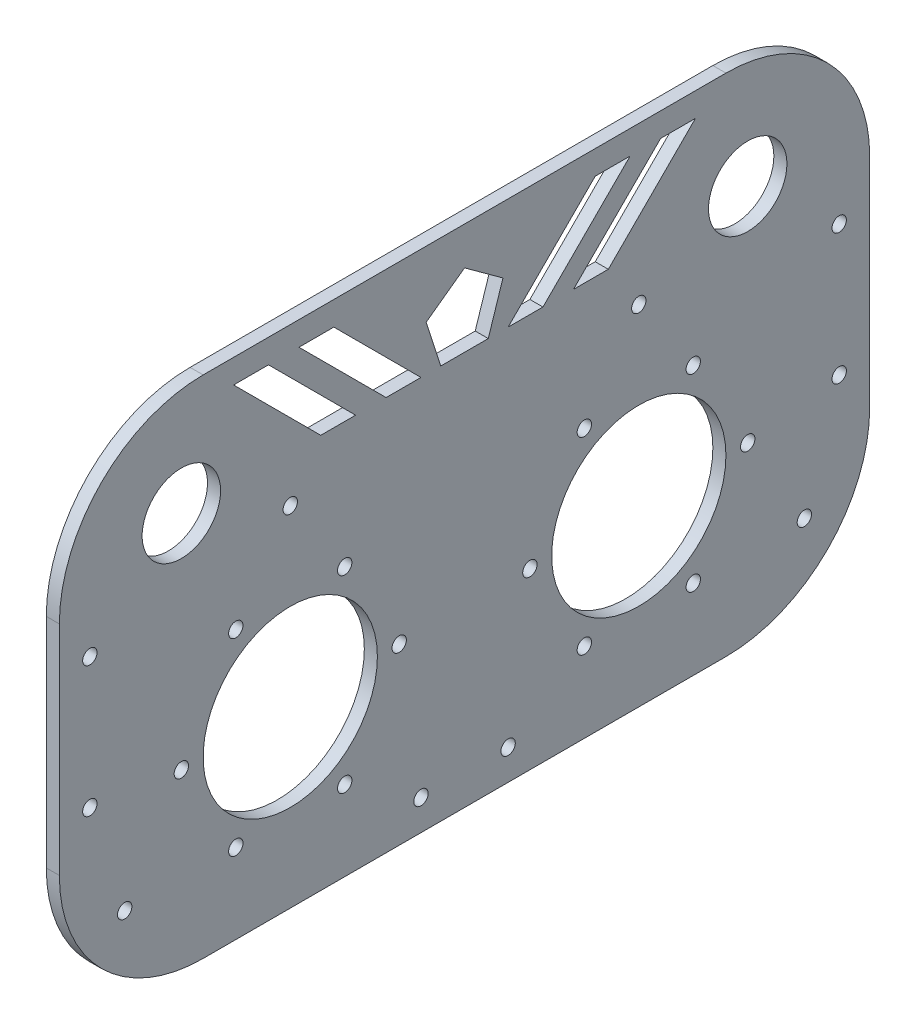
from build123d import *

# Parameters (mm, degrees)
SKETCH_1_W           = 120
SKETCH_1_H           = 83
SKETCH_1_H_2         = 33
EXTRUDE_2_DEPTH      = 3
SKETCH_2_R           = 1.65
SKETCH_2_R_2         = 20
CUT_EXTRUDE_1_DEPTH  = 3
SKETCH_3_R           = 1.65
CUT_EXTRUDE_2_DEPTH  = 10
SKETCH_4_R           = 1.65
CUT_EXTRUDE_3_DEPTH  = 5
CUT_EXTRUDE_6_DEPTH  = 3
SKETCH_9_W           = 5
SKETCH_9_H           = 5
EXTRUDE_4_DEPTH      = 2.25
SKETCH_8_R           = 1.65
CUT_EXTRUDE_9_DEPTH  = 7
SKETCH_11_R          = 9
CUT_EXTRUDE_10_DEPTH = 10


with BuildPart() as part:
    # 草图1 → 凸台-拉伸2 (new body)
    with BuildSketch(Plane(origin=(0, 0, 0), x_dir=(0, 0, -1), z_dir=(1, 0, 0))):
        with Locations((0, -16.5)):
            Rectangle(SKETCH_1_W, SKETCH_1_H)
        with Locations((0, 41.5)):
            Rectangle(SKETCH_1_W, SKETCH_1_H_2)
        with BuildLine():
            Line((-60, -58), (-60, 58))
            ThreePointArc((-60, 58), (-83.334523779, 48.334523779), (-93, 25))
            Line((-93, 25), (-93, -25))
            ThreePointArc((-93, -25), (-83.334523779, -48.334523779), (-60, -58))
        make_face()
        with BuildLine():
            ThreePointArc((60, 58), (83.334523779, 48.334523779), (93, 25))
            Line((93, 25), (93, -25))
            ThreePointArc((93, -25), (83.334523779, -48.334523779), (60, -58))
            Line((60, -58), (60, 58))
        make_face()
    extrude(amount=EXTRUDE_2_DEPTH)

    # 草图2 → 切除-拉伸1 (cut)
    with BuildSketch(Plane(origin=(3, 0, 0), x_dir=(0, 0, -1), z_dir=(1, 0, 0))):
        with Locations((-52.5, -39.650635095)):
            Circle(SKETCH_2_R)
        with Locations((40, -18)):
            Circle(SKETCH_2_R_2)
        with Locations((-40, -18)):
            Circle(SKETCH_2_R_2)
        with Locations((-52.5, 3.650635095)):
            Circle(SKETCH_2_R)
        with Locations((-65, -18)):
            Circle(SKETCH_2_R)
        with Locations((-27.5, -39.650635095)):
            Circle(SKETCH_2_R)
        with Locations((-15, -18)):
            Circle(SKETCH_2_R)
        with Locations((15, -18)):
            Circle(SKETCH_2_R)
        with Locations((27.5, 3.650635095)):
            Circle(SKETCH_2_R)
        with Locations((52.5, 3.650635095)):
            Circle(SKETCH_2_R)
        with Locations((65, -18)):
            Circle(SKETCH_2_R)
        with Locations((52.5, -39.650635095)):
            Circle(SKETCH_2_R)
        with Locations((27.5, -39.650635095)):
            Circle(SKETCH_2_R)
        with Locations((-27.5, 3.650635095)):
            Circle(SKETCH_2_R)
        with Locations((-40, 22)):
            Circle(SKETCH_2_R)
        with Locations((40, 22)):
            Circle(SKETCH_2_R)
    extrude(amount=-CUT_EXTRUDE_1_DEPTH, mode=Mode.SUBTRACT)

    # 草图3 → 切除-拉伸2 (cut)
    with BuildSketch(Plane(origin=(3, 0, 0), x_dir=(0, 0, -1), z_dir=(1, 0, 0))):
        with Locations((-10, -51)):
            Circle(SKETCH_3_R)
        with Locations((10, -51)):
            Circle(SKETCH_3_R)
    extrude(amount=-CUT_EXTRUDE_2_DEPTH, mode=Mode.SUBTRACT)

    # 草图4 → 切除-拉伸3 (cut)
    with BuildSketch(Plane.ZY):
        with Locations((86, 15)):
            Circle(SKETCH_4_R)
        with Locations((86, -15)):
            Circle(SKETCH_4_R)
        with Locations((-86, 15)):
            Circle(SKETCH_4_R)
        with Locations((-86, -15)):
            Circle(SKETCH_4_R)
    extrude(amount=-CUT_EXTRUDE_3_DEPTH, mode=Mode.SUBTRACT)

    # 草图6 → 切除-拉伸6 (cut)
    with BuildSketch(Plane.ZY):
        Polygon((-25, 32.5), (-33, 32.5), (-53, 52.5), (-45, 52.5), align=None)
        Polygon((0, 49.270509831), (-8.816778784, 42.864745084), (-5.44906896, 32.5), (5.44906896, 32.5), (8.816778784, 42.864745084), align=None)
        Polygon((-10, 32.5), (-18, 32.5), (-38, 52.5), (-30, 52.5), align=None)
        Polygon((38, 52.5), (30, 52.5), (10, 32.5), (18, 32.5), align=None)
        Polygon((53, 52.5), (45, 52.5), (25, 32.5), (33, 32.5), align=None)
    extrude(amount=-CUT_EXTRUDE_6_DEPTH, mode=Mode.SUBTRACT)

    # 草图9 → 凸台-拉伸4 (add)
    with BuildSketch(Plane.ZY):
        with Locations((-78, -39.5)):
            Rectangle(SKETCH_9_W, SKETCH_9_H)
        with Locations((78, -39.5)):
            Rectangle(SKETCH_9_W, SKETCH_9_H)
    extrude(amount=EXTRUDE_4_DEPTH)

    # 草图8 → 切除-拉伸9 (cut)
    with BuildSketch(Plane(origin=(3, 0, 0), x_dir=(0, 0, -1), z_dir=(1, 0, 0))):
        with Locations((78, -39.5)):
            Circle(SKETCH_8_R)
        with Locations((-78, -39.5)):
            Circle(SKETCH_8_R)
    extrude(amount=-CUT_EXTRUDE_9_DEPTH, mode=Mode.SUBTRACT)

    # 草图11 → 切除-拉伸10 (cut)
    with BuildSketch(Plane(origin=(3, 0, 0), x_dir=(0, 0, -1), z_dir=(1, 0, 0))):
        with Locations((-65, 33)):
            Circle(SKETCH_11_R)
        with Locations((65, 33)):
            Circle(SKETCH_11_R)
    extrude(amount=-CUT_EXTRUDE_10_DEPTH, mode=Mode.SUBTRACT)


solid = part.part
